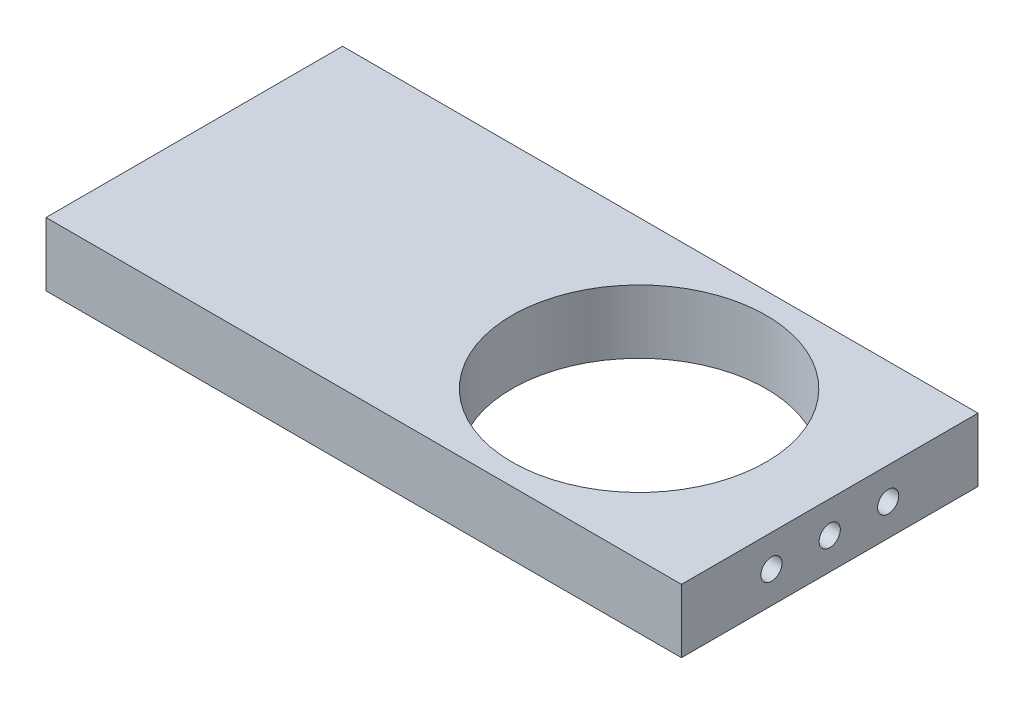
from build123d import *

# Parameters (mm, degrees)
SKETCH1_W           = 190.5
SKETCH1_H           = 88.9
SKETCH1_R           = 38.1
BOSS_EXTRUDE1_DEPTH = 9.525
SKETCH2_R           = 3.175
CUT_EXTRUDE1_DEPTH  = 12.7


with BuildPart() as part:
    # Sketch1 → Boss-Extrude1 (new body, symmetric)
    with BuildSketch(Plane(origin=(0, 0, 0), x_dir=(1, 0, 0), z_dir=(0, 1, 0))):
        Rectangle(SKETCH1_W, SKETCH1_H)
        with Locations((38.1, 0)):
            Circle(SKETCH1_R, mode=Mode.SUBTRACT)
    extrude(amount=BOSS_EXTRUDE1_DEPTH, both=True)

    # Sketch2 → Cut-Extrude1 (cut)
    with BuildSketch(Plane(origin=(95.25, 0, 0), x_dir=(0, 0, -1), z_dir=(1, 0, 0))):
        Circle(SKETCH2_R)
        with Locations((17.526, 0)):
            Circle(SKETCH2_R)
        with Locations((-17.4625, 0)):
            Circle(SKETCH2_R)
    cut_extrude1 = extrude(amount=-CUT_EXTRUDE1_DEPTH, mode=Mode.SUBTRACT)

    # Mirror1: Cut-Extrude1 across plane
    add(cut_extrude1.mirror(Plane(origin=(0, 0, 0), x_dir=(0, 0, 1), z_dir=(1, 0, 0))), mode=Mode.SUBTRACT)


solid = part.part
